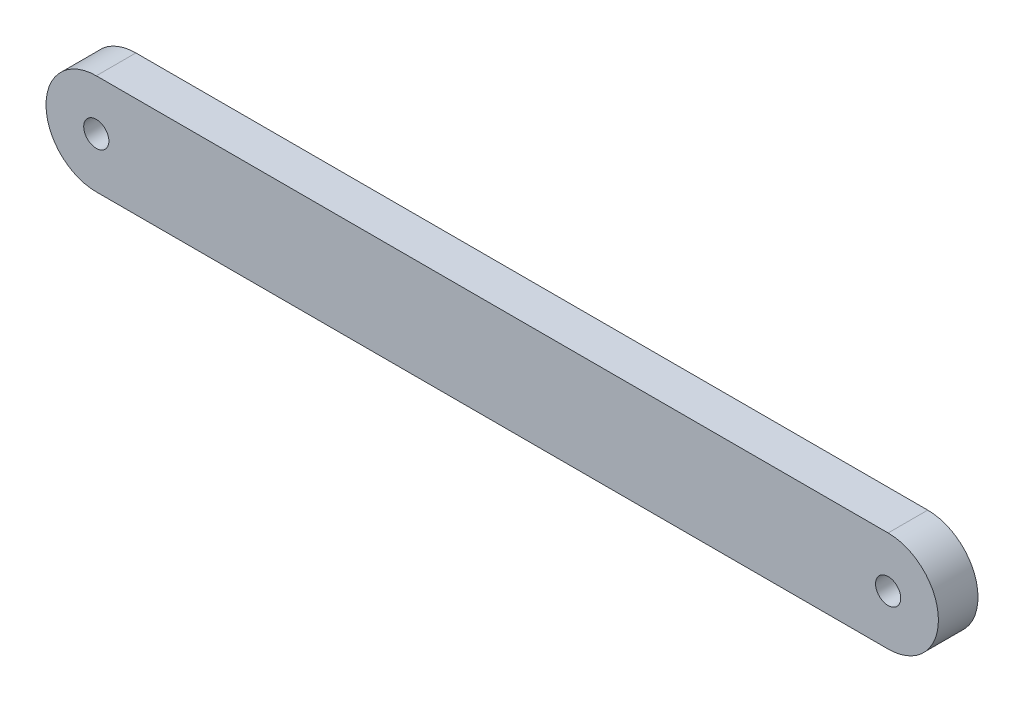
from build123d import *

# Parameters (mm, degrees)
SKETCH1_R           = 3.175
BOSS_EXTRUDE1_DEPTH = 10


with BuildPart() as part:
    # Sketch1 → Boss-Extrude1 (new body)
    with BuildSketch(Plane.XY):
        with BuildLine():
            Line((0, 12.7), (200, 12.7))
            ThreePointArc((200, 12.7), (212.7, 0), (200, -12.7))
            Line((200, -12.7), (0, -12.7))
            ThreePointArc((0, -12.7), (-12.7, 0), (0, 12.7))
        make_face()
        Circle(SKETCH1_R, mode=Mode.SUBTRACT)
        with Locations((200, 0)):
            Circle(SKETCH1_R, mode=Mode.SUBTRACT)
    extrude(amount=BOSS_EXTRUDE1_DEPTH)


solid = part.part
